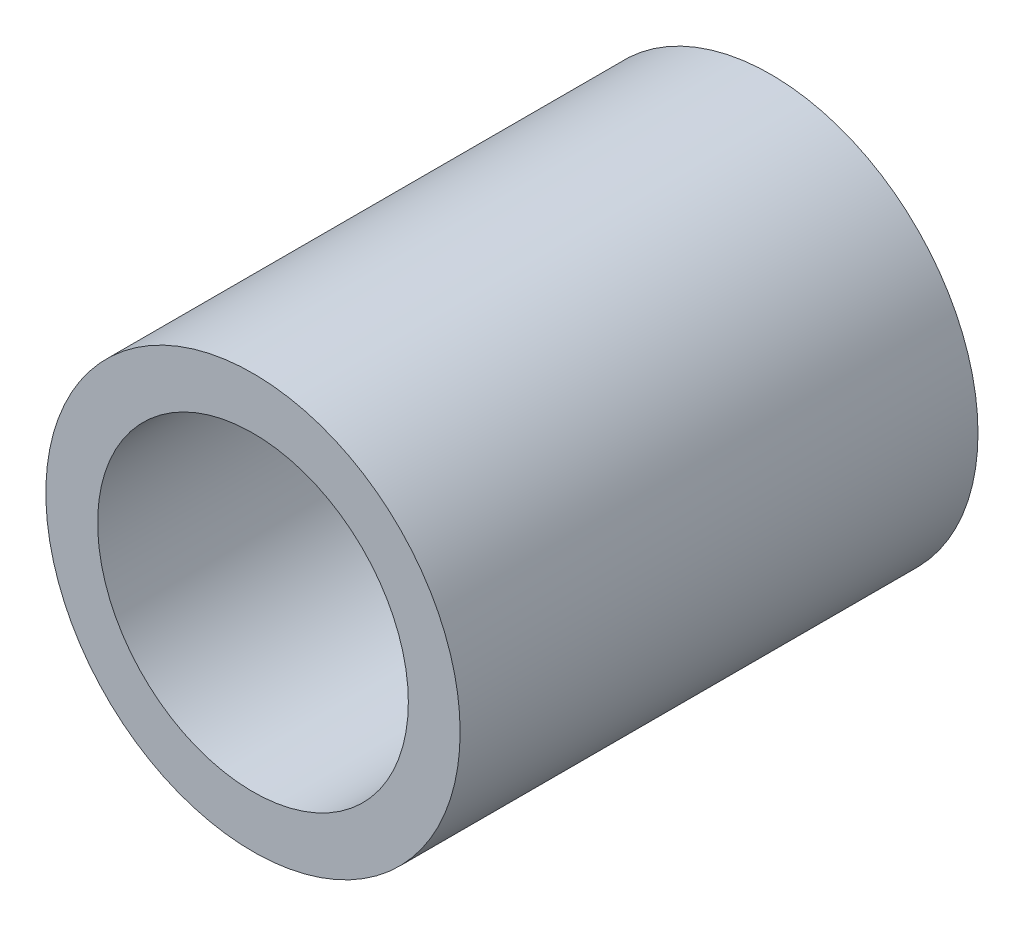
from build123d import *

# Parameters (mm, degrees)
SKETCH2_R           = 8
SKETCH2_R_2         = 6
BOSS_EXTRUDE1_DEPTH = 10


with BuildPart() as part:
    # Sketch2 → Boss-Extrude1 (new, symmetric)
    with BuildSketch(Plane.XY):
        Circle(SKETCH2_R)
        Circle(SKETCH2_R_2, mode=Mode.SUBTRACT)
    extrude(amount=BOSS_EXTRUDE1_DEPTH, both=True)


solid = part.part
